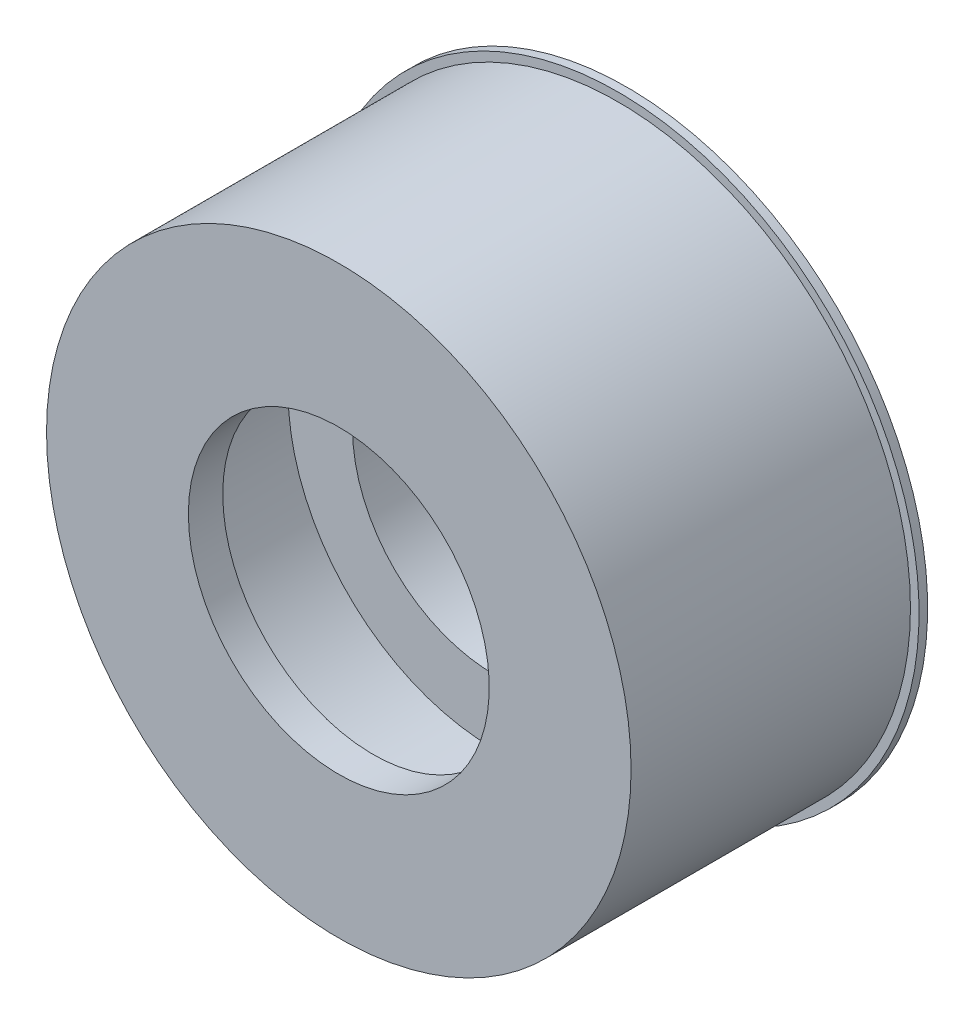
from build123d import *


with BuildPart() as part:
    # Sketch2 → Revolve1 (revolve)
    with BuildSketch(Plane(origin=(0, 0, 0), x_dir=(1, 0, 0), z_dir=(0, 1, 0))):
        Polygon((-3.5, -6.7), (-3.5, -5.9), (-4.8, -5.58), (-4.8, -3.08), (-3.3, -3.08), (-3.3, -1), (-5, -1), (-5, -0.4), (-5.3, -0.4), (-5.3, 0), (-7, 0), (-7, -0.2), (-6.8, -0.2), (-6.8, -6.7), align=None)
    revolve(axis=Axis((0, 0, 0), (0, 0, 1)))


solid = part.part
